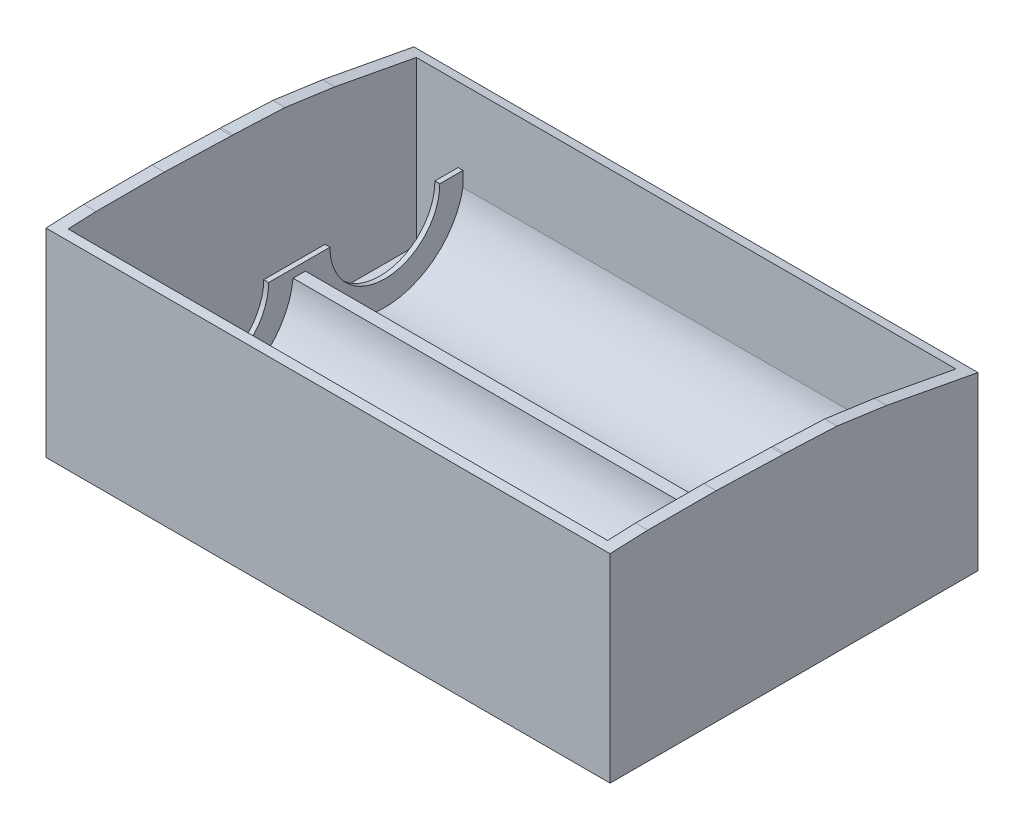
from build123d import *

# Parameters (mm, degrees)
BOSS_EXTRUDE6_DEPTH = 115
CUT_EXTRUDE5_START  = 2
SKETCH17_W          = 110
SKETCH17_H          = 71
CUT_EXTRUDE5_DEPTH  = 115
BOSS_EXTRUDE7_START = -12
BOSS_EXTRUDE7_DEPTH = 91
SKETCH22_R          = 3
SKETCH22_W          = 91
SKETCH22_H          = 3.970785373
CUT_EXTRUDE6_DEPTH  = 3.191306198
BOSS_EXTRUDE8_START = -12
SKETCH23_W          = 67.315835607
SKETCH23_H          = 18
BOSS_EXTRUDE8_DEPTH = 1
BOSS_EXTRUDE9_START = -12
SKETCH24_W          = 67.315835607
SKETCH24_H          = 18
BOSS_EXTRUDE9_DEPTH = 1
CUT_EXTRUDE7_DEPTH  = 1
CUT_EXTRUDE8_DEPTH  = 1


with BuildPart() as part:
    # Sketch16 → Boss-Extrude6 (new body)
    with BuildSketch(Plane(origin=(0, 0, 0), x_dir=(0, 0, -1), z_dir=(1, 0, 0))):
        Polygon((21.546513219, 40.639365956), (7.618622676, 40.639365956), (-0.073583226, 40.318426006), (-0.073583226, -0.191306198), (74.926416774, -0.191306198), (74.926416774, 34.808693802), (56.287613548, 38.312228243), (46.171210173, 39.731159859), (35.60256896, 40.205500696), (35.23833782, 40.205500696), align=None)
    extrude(amount=BOSS_EXTRUDE6_DEPTH)

    # Sketch17 → Cut-Extrude5 (cut)
    with BuildSketch(Plane(origin=(0, 0, 0), x_dir=(1, 0, 0), z_dir=(0, 1, 0)).offset(CUT_EXTRUDE5_START)):
        with Locations((57.5, 37.426416774)):
            Rectangle(SKETCH17_W, SKETCH17_H)
    extrude(amount=CUT_EXTRUDE5_DEPTH, mode=Mode.SUBTRACT)

    # Sketch21 → Boss-Extrude7 (add)
    with BuildSketch(Plane.ZY.offset(BOSS_EXTRUDE7_START)):
        with BuildLine():
            Line((-73.213037754, 2), (-73.213037754, 20))
            ThreePointArc((-73.213037754, 20), (-57.828004717, 3.773036878), (-40.805119951, 18.272518522))
            Line((-40.805119951, 18.272518522), (-38.305119951, 18.272518522))
            ThreePointArc((-38.305119951, 18.272518522), (-21.282235184, 3.773036878), (-5.897202147, 20))
            Line((-5.897202147, 20), (-5.897202147, 2))
            Line((-5.897202147, 2), (-73.213037754, 2))
        make_face()
    extrude(amount=-BOSS_EXTRUDE7_DEPTH)

    # Sketch22 → Cut-Extrude6 (cut, through all)
    with BuildSketch(Plane(origin=(0, 2, 0), x_dir=(1, 0, 0), z_dir=(0, 1, 0))):
        with Locations((7, 69.426416774)):
            Circle(SKETCH22_R)
        with Locations((108, 69.426416774)):
            Circle(SKETCH22_R)
        with Locations((108, 5.426416774)):
            Circle(SKETCH22_R)
        with Locations((7, 5.426416774)):
            Circle(SKETCH22_R)
        with Locations((57.5, 3.911809461)):
            Rectangle(SKETCH22_W, SKETCH22_H)
    extrude(amount=-CUT_EXTRUDE6_DEPTH, mode=Mode.SUBTRACT)

    # Sketch23 → Boss-Extrude8 (add)
    with BuildSketch(Plane.ZY.offset(BOSS_EXTRUDE8_START)):
        with Locations((-39.55511995, 11)):
            Rectangle(SKETCH23_W, SKETCH23_H)
    extrude(amount=BOSS_EXTRUDE8_DEPTH)

    # Sketch24 → Boss-Extrude9 (add)
    with BuildSketch(Plane(origin=(115, 0, 0), x_dir=(0, 0, -1), z_dir=(1, 0, 0)).offset(BOSS_EXTRUDE9_START)):
        with Locations((39.55511995, 11)):
            Rectangle(SKETCH24_W, SKETCH24_H)
    extrude(amount=BOSS_EXTRUDE9_DEPTH)

    # Sketch25 → Cut-Extrude7 (cut)
    with BuildSketch(Plane.ZY.offset(-11)):
        with BuildLine():
            Line((-68.205119951, 20), (-45.805119951, 20))
            ThreePointArc((-45.805119951, 20), (-57.005119951, 8.8), (-68.205119951, 20))
        make_face()
        with BuildLine():
            Line((-33.305119951, 20), (-10.905119951, 20))
            ThreePointArc((-10.905119951, 20), (-22.105119951, 8.8), (-33.305119951, 20))
        make_face()
    extrude(amount=-CUT_EXTRUDE7_DEPTH, mode=Mode.SUBTRACT)

    # Sketch26 → Cut-Extrude8 (cut)
    with BuildSketch(Plane(origin=(104, 0, 0), x_dir=(0, 0, -1), z_dir=(1, 0, 0))):
        with BuildLine():
            Line((10.905119951, 20), (33.305119951, 20))
            ThreePointArc((33.305119951, 20), (22.105119951, 8.8), (10.905119951, 20))
        make_face()
        with BuildLine():
            Line((45.805119951, 20), (68.205119951, 20))
            ThreePointArc((68.205119951, 20), (57.005119951, 8.8), (45.805119951, 20))
        make_face()
    extrude(amount=-CUT_EXTRUDE8_DEPTH, mode=Mode.SUBTRACT)


solid = part.part
